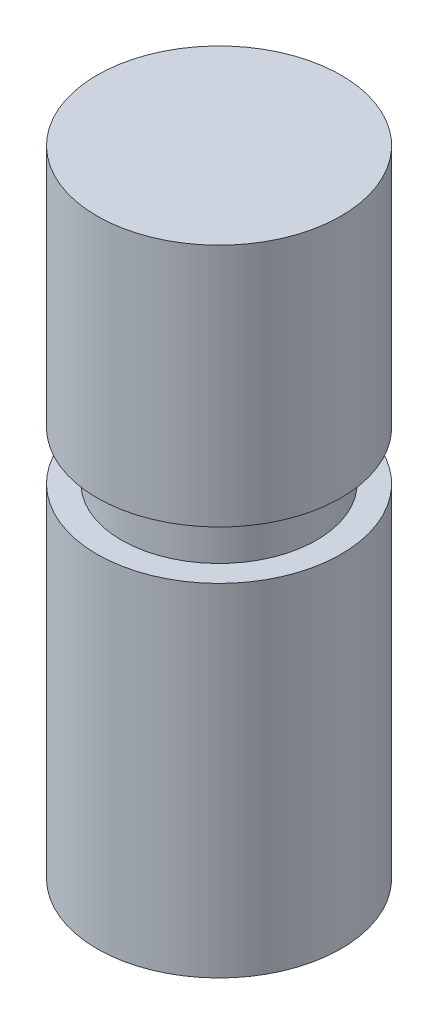
from build123d import *

# Parameters (mm, degrees)
SKETCH_4_R      = 25
EXTRUDE_1_DEPTH = 50
SKETCH_5_R      = 20
EXTRUDE_2_DEPTH = 50
SKETCH_6_R      = 25
EXTRUDE_3_DEPTH = 70


with BuildPart() as part:
    # 草图4 → 凸台-拉伸1 (new body)
    with BuildSketch(Plane(origin=(0, 50, 0), x_dir=(1, 0, 0), z_dir=(0, 1, 0))):
        Circle(SKETCH_4_R)
    extrude(amount=-EXTRUDE_1_DEPTH)

    # 草图5 → 凸台-拉伸2 (add)
    with BuildSketch(Plane(origin=(0, -10, 0), x_dir=(1, 0, 0), z_dir=(0, 1, 0))):
        Circle(SKETCH_5_R)
    extrude(amount=EXTRUDE_2_DEPTH)

    # 草图6 → 凸台-拉伸3 (add)
    with BuildSketch(Plane(origin=(0, -80, 0), x_dir=(1, 0, 0), z_dir=(0, 1, 0))):
        Circle(SKETCH_6_R)
    extrude(amount=EXTRUDE_3_DEPTH)


solid = part.part
